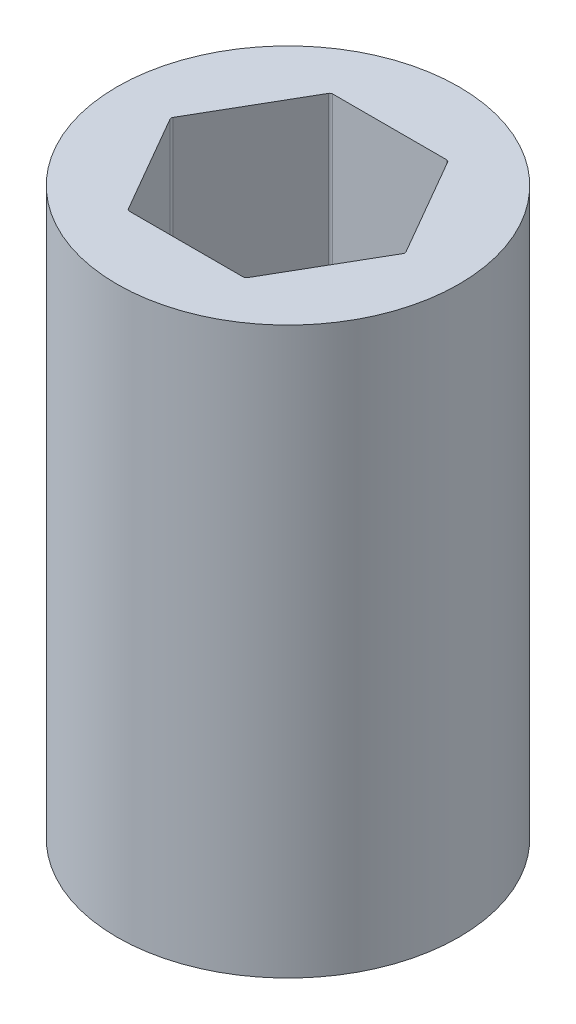
from build123d import *

# Parameters (mm, degrees)
SKETCH1_R           = 11.1125
BOSS_EXTRUDE1_DEPTH = 36.7538
FILLET1_R           = 0.2


with BuildPart() as part:
    # Sketch1 → Boss-Extrude1 (new body)
    with BuildSketch(Plane(origin=(0, 0, 0), x_dir=(1, 0, 0), z_dir=(0, 1, 0))):
        Circle(SKETCH1_R)
        Polygon((7.625642355, 0), (3.812821178, 6.604), (-3.812821178, 6.604), (-7.625642355, 0), (-3.812821178, -6.604), (3.812821178, -6.604), align=None, mode=Mode.SUBTRACT)
    extrude(amount=BOSS_EXTRUDE1_DEPTH)

    # Fillet1
    fillet1_edges = [part.edges().sort_by_distance(p)[0] for p in [
        (7.625642355, 18.3769, 0),
        (3.812821178, 18.3769, -6.604),
        (-3.812821178, 18.3769, -6.604),
        (-7.625642355, 18.3769, 0),
        (-3.812821178, 18.3769, 6.604),
        (3.812821178, 18.3769, 6.604),
    ]]
    fillet(fillet1_edges, radius=FILLET1_R)


solid = part.part
